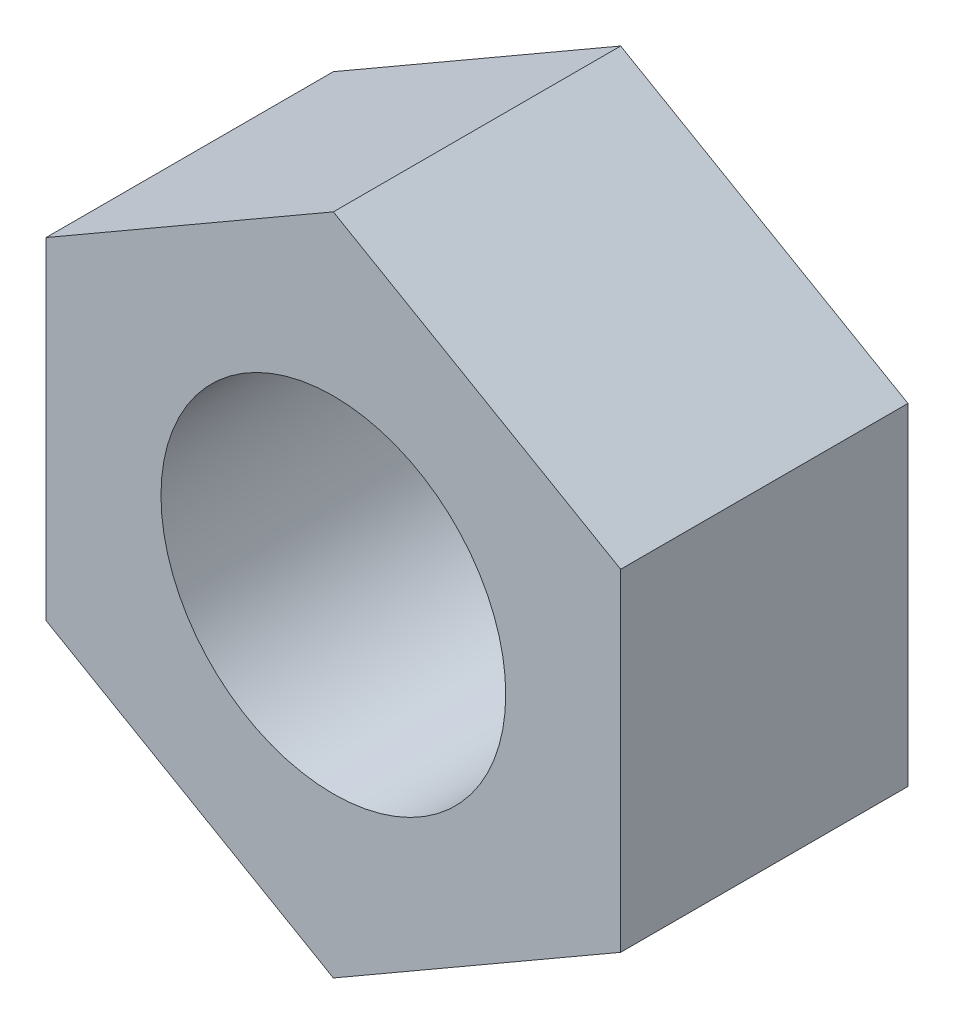
from build123d import *

# Parameters (mm, degrees)
SKETCH1_R           = 3
BOSS_EXTRUDE1_DEPTH = 5


with BuildPart() as part:
    # Sketch1 → Boss-Extrude1 (new body)
    with BuildSketch(Plane.XY):
        Polygon((5, -2.886751346), (5, 2.886751346), (0, 5.773502692), (-5, 2.886751346), (-5, -2.886751346), (0, -5.773502692), align=None)
        Circle(SKETCH1_R, mode=Mode.SUBTRACT)
    extrude(amount=BOSS_EXTRUDE1_DEPTH)


solid = part.part
